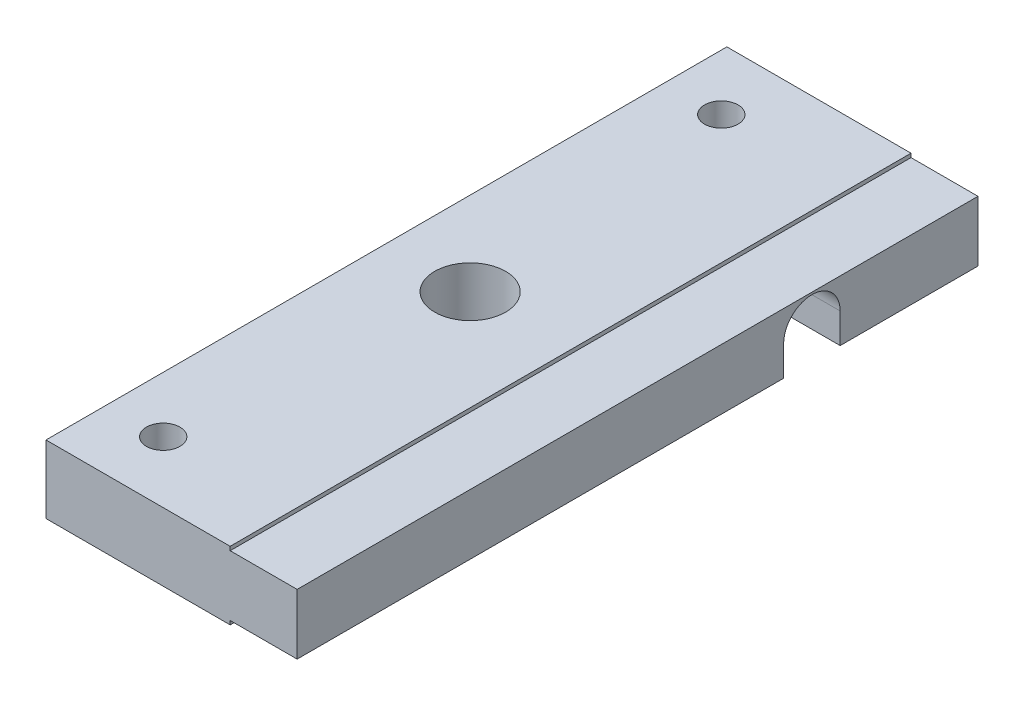
from build123d import *

# Parameters (mm, degrees)
SKETCH1_W           = 61
SKETCH1_H           = 6.1
BOSS_EXTRUDE1_DEPTH = 22.5
SKETCH2_OUTSIDE_W   = 76.06
SKETCH2_OUTSIDE_H   = 21.16
SKETCH2_OUTSIDE_W_2 = 61
SKETCH2_OUTSIDE_H_2 = 5.41284
CUT_EXTRUDE1_DEPTH  = 6
CUT_EXTRUDE3_DEPTH  = 23.5
SKETCH6_R           = 3.175
CUT_EXTRUDE4_DEPTH  = 7.1
SKETCH7_R           = 1.5
CUT_EXTRUDE5_DEPTH  = 7.1


with BuildPart() as part:
    # Sketch1 → Boss-Extrude1 (new body)
    with BuildSketch(Plane(origin=(0, 0, 0), x_dir=(0, 0, -1), z_dir=(1, 0, 0))):
        with Locations((30.5, 0)):
            Rectangle(SKETCH1_W, SKETCH1_H)
    extrude(amount=BOSS_EXTRUDE1_DEPTH)

    # Sketch2 outside → Cut-Extrude1 (cut)
    with BuildSketch(Plane(origin=(22.5, 0, 0), x_dir=(0, 0, -1), z_dir=(1, 0, 0))):
        with Locations((30.5, 0)):
            Rectangle(SKETCH2_OUTSIDE_W, SKETCH2_OUTSIDE_H)
        with Locations((30.5, 0)):
            Rectangle(SKETCH2_OUTSIDE_W_2, SKETCH2_OUTSIDE_H_2, mode=Mode.SUBTRACT)
    extrude(amount=-CUT_EXTRUDE1_DEPTH, mode=Mode.SUBTRACT)

    # Sketch5 → Cut-Extrude3 (cut, through all)
    with BuildSketch(Plane.ZY):
        with BuildLine():
            Line((-43.5866, -0.01898), (-43.5866, -3.05))
            Line((-43.5866, -3.05), (-48.6514, -3.05))
            Line((-48.6514, -3.05), (-48.6514, -0.01898))
            ThreePointArc((-48.6514, -0.01898), (-46.119, 2.51342), (-43.5866, -0.01898))
        make_face()
    extrude(amount=-CUT_EXTRUDE3_DEPTH, mode=Mode.SUBTRACT)

    # Sketch6 → Cut-Extrude4 (cut, through all)
    with BuildSketch(Plane(origin=(0, 3.05, 0), x_dir=(1, 0, 0), z_dir=(0, 1, 0))):
        with Locations(Location((7.5, 30.5, 0), (0, 0, 270))):  # turned: the seam where the file's is
            Circle(SKETCH6_R)
    extrude(amount=-CUT_EXTRUDE4_DEPTH, mode=Mode.SUBTRACT)

    # Sketch7 → Cut-Extrude5 (cut, through all)
    with BuildSketch(Plane(origin=(0, 3.05, 0), x_dir=(1, 0, 0), z_dir=(0, 1, 0))):
        with Locations(Location((5, 55.5, 0), (0, 0, 270))):  # turned: the seam where the file's is
            Circle(SKETCH7_R)
        with Locations(Location((5, 5.5, 0), (0, 0, 270))):  # turned: the seam where the file's is
            Circle(SKETCH7_R)
    extrude(amount=-CUT_EXTRUDE5_DEPTH, mode=Mode.SUBTRACT)


solid = part.part
